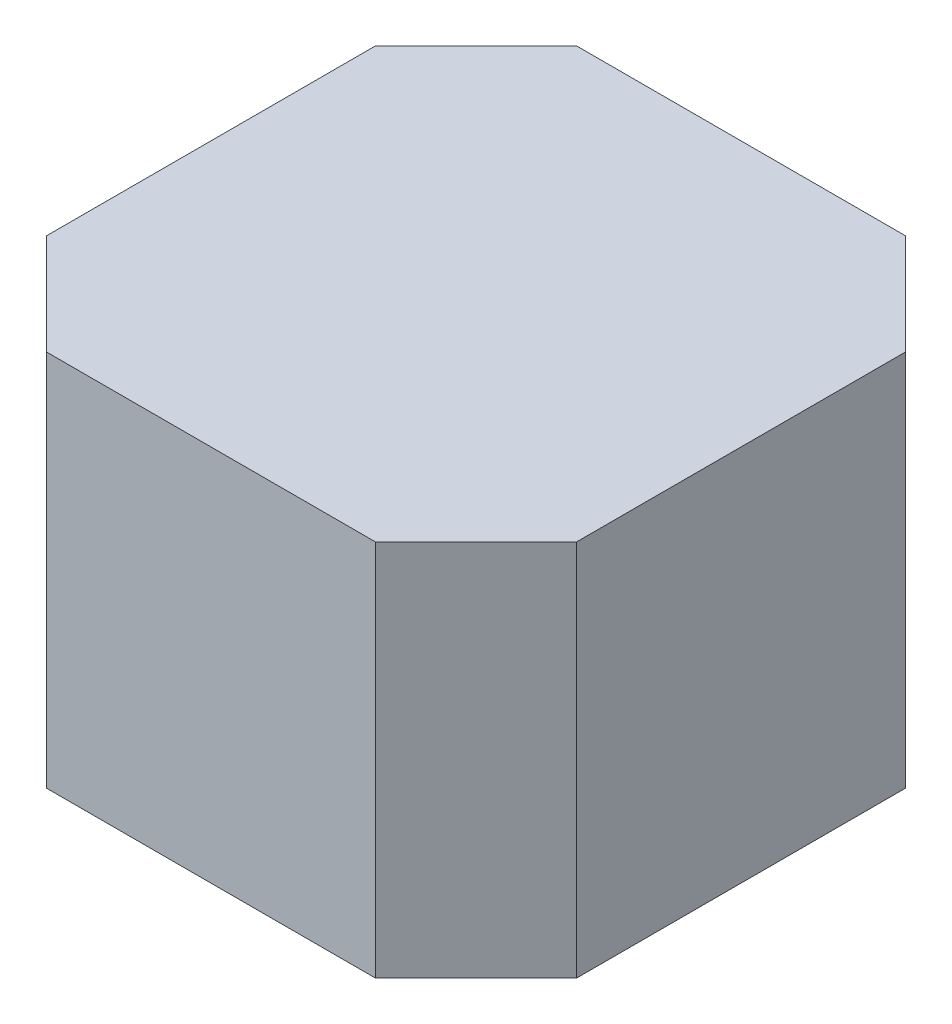
from build123d import *

# Parameters (mm, degrees)
SKETCH1_W           = 42.1
SKETCH1_H           = 42.1
BOSS_EXTRUDE1_DEPTH = 30
CHAMFER2_SIZE       = 8


with BuildPart() as part:
    # Sketch1 → Boss-Extrude1 (new body)
    with BuildSketch(Plane(origin=(0, 0, 0), x_dir=(1, 0, 0), z_dir=(0, 1, 0))):
        Rectangle(SKETCH1_W, SKETCH1_H)
    extrude(amount=BOSS_EXTRUDE1_DEPTH)

    # Chamfer2
    chamfer2_edges = [part.edges().sort_by_distance(p)[0] for p in [
        (21.05, 15, 21.05),
        (-21.05, 15, 21.05),
        (-21.05, 15, -21.05),
        (21.05, 15, -21.05),
    ]]
    chamfer(chamfer2_edges, length=CHAMFER2_SIZE)


solid = part.part
